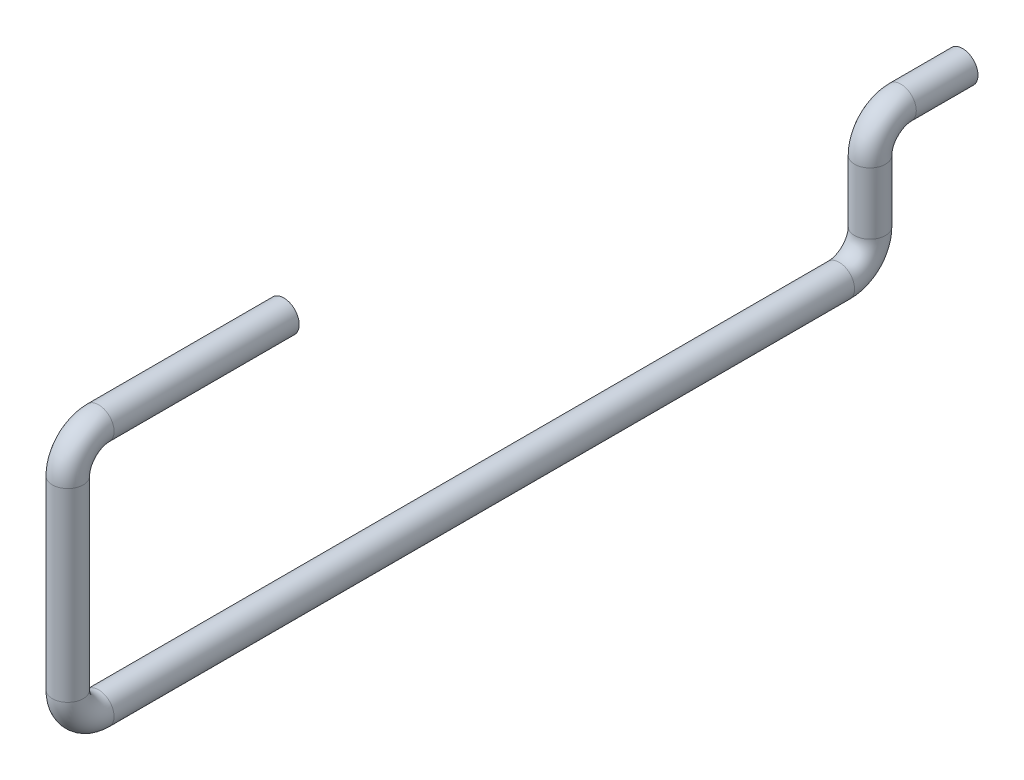
from build123d import *

# Parameters (mm, degrees)
SKETCH3_R = 0.5


with BuildPart() as part:
    # Sweep2: sweep along a path in Sketch1
    with BuildLine(Plane(origin=(0, 0, 0), x_dir=(0, 0, -1), z_dir=(1, 0, 0))) as sweep2_path:
        Line((16, 4), (14, 4))
        ThreePointArc((14, 4), (13.292893219, 3.707106781), (13, 3))
        Line((13, 3), (13, 1))
        ThreePointArc((13, 1), (12.707106781, 0.292893219), (12, 0))
        Line((12, 0), (-12, 0))
        ThreePointArc((-12, 0), (-12.707106781, 0.292893219), (-13, 1))
        Line((-13, 1), (-13, 7))
        ThreePointArc((-13, 7), (-12.707106781, 7.707106781), (-12, 8))
        Line((-12, 8), (-6, 8))
    # Sketch3 → Sweep2 (sweep)
    with BuildSketch(Plane.XY):
        Circle(SKETCH3_R)
    sweep(path=sweep2_path.line)


solid = part.part
